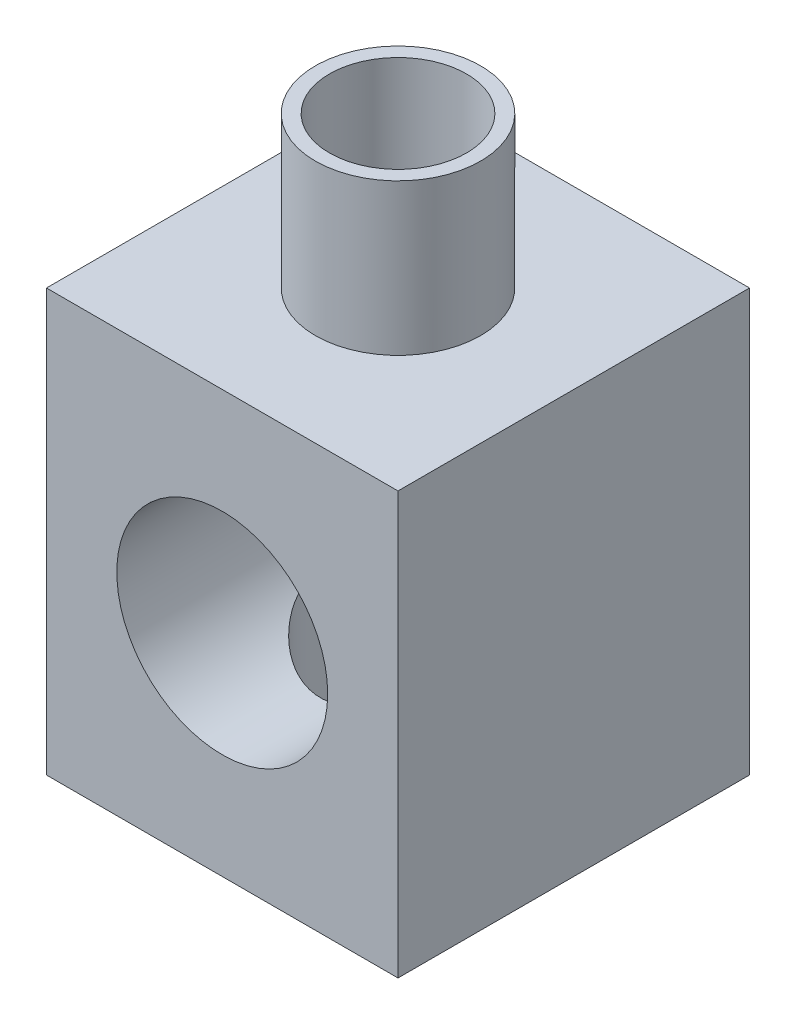
from build123d import *

# Parameters (mm, degrees)
CROQUIS1_W                   = 50
CROQUIS1_H                   = 50
CROQUIS1_R                   = 11
SALIENTE_EXTRUIR1_DEPTH      = 60
CROQUIS3_R                   = 15
CORTAR_EXTRUIR1_DEPTH        = 47
CROQUIS4_R                   = 4
CORTAR_EXTRUIR2_DEPTH        = 10
CROQUIS5_R                   = 11.75
CROQUIS5_R_2                 = 9.75
SALIENTE_EXTRUIR3_DEPTH      = 21.5
SALIENTE_EXTRUIR3_DEPTH_BACK = 5
CROQUIS7_R                   = 13
CROQUIS7_R_2                 = 11
SALIENTE_EXTRUIR4_DEPTH      = 10


with BuildPart() as part:
    # Croquis1 → Saliente-Extruir1 (new body)
    with BuildSketch(Plane(origin=(0, 0, 0), x_dir=(1, 0, 0), z_dir=(0, 1, 0))):
        Rectangle(CROQUIS1_W, CROQUIS1_H)
        Circle(CROQUIS1_R, mode=Mode.SUBTRACT)
    extrude(amount=SALIENTE_EXTRUIR1_DEPTH)

    # Croquis3 → Cortar-Extruir1 (cut)
    with BuildSketch(Plane.XY.offset(25)):
        with Locations((0, 30)):
            Circle(CROQUIS3_R)
    extrude(amount=-CORTAR_EXTRUIR1_DEPTH, mode=Mode.SUBTRACT)

    # Croquis4 → Cortar-Extruir2 (cut)
    with BuildSketch(Plane.XY.offset(-22)):
        with Locations((0, 30)):
            Circle(CROQUIS4_R)
    extrude(amount=-CORTAR_EXTRUIR2_DEPTH, mode=Mode.SUBTRACT)

    # Croquis5 → Saliente-Extruir3 (add, two sides)
    with BuildSketch(Plane(origin=(0, 60, 0), x_dir=(1, 0, 0), z_dir=(0, 1, 0))) as saliente_extruir3_sk:
        Circle(CROQUIS5_R)
        Circle(CROQUIS5_R_2, mode=Mode.SUBTRACT)
    extrude(amount=SALIENTE_EXTRUIR3_DEPTH)
    extrude(saliente_extruir3_sk.sketch, amount=-SALIENTE_EXTRUIR3_DEPTH_BACK)

    # Croquis7 → Saliente-Extruir4 (add)
    with BuildSketch(Plane.XZ):
        Circle(CROQUIS7_R)
        Circle(CROQUIS7_R_2, mode=Mode.SUBTRACT)
    extrude(amount=SALIENTE_EXTRUIR4_DEPTH)


solid = part.part
